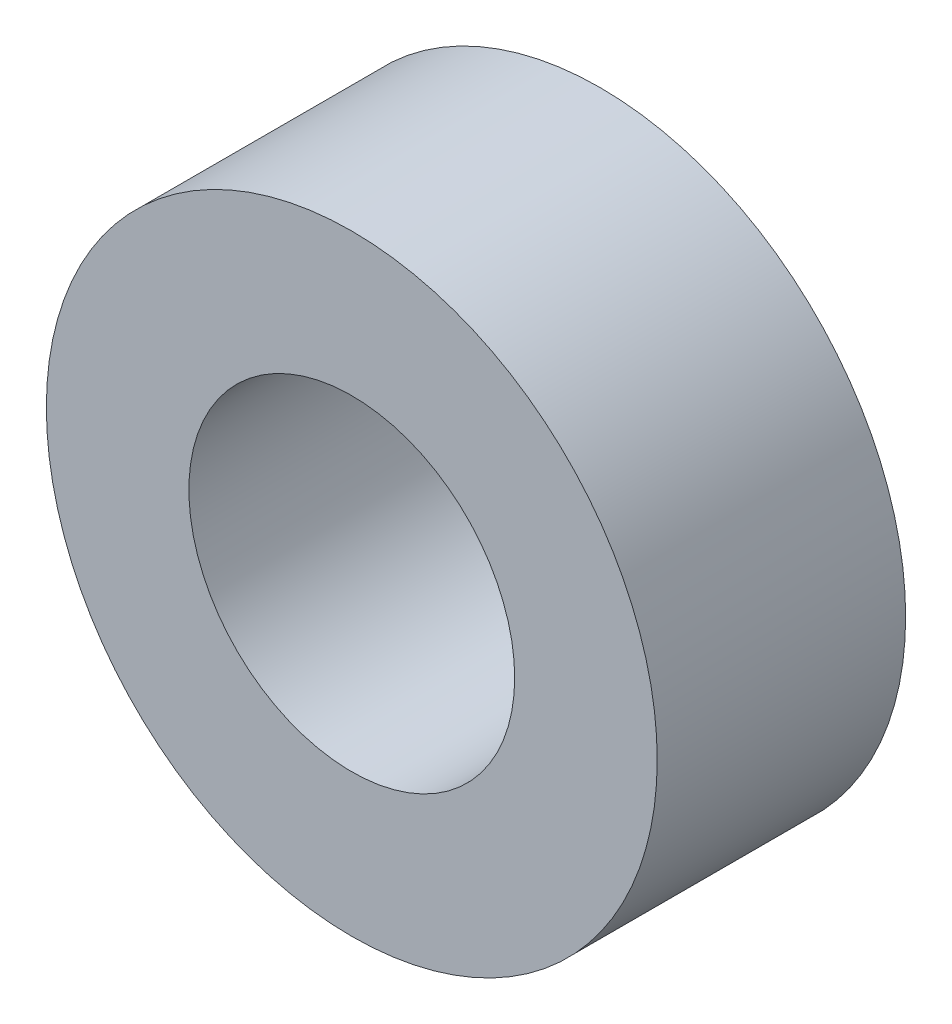
from build123d import *

# Parameters (mm, degrees)
CROQUIS1_R              = 7.5
CROQUIS1_R_2            = 4
SALIENTE_EXTRUIR1_DEPTH = 6.1


with BuildPart() as part:
    # Croquis1 → Saliente-Extruir1 (new body)
    with BuildSketch(Plane.XY):
        Circle(CROQUIS1_R)
        Circle(CROQUIS1_R_2, mode=Mode.SUBTRACT)
    extrude(amount=SALIENTE_EXTRUIR1_DEPTH)


solid = part.part
